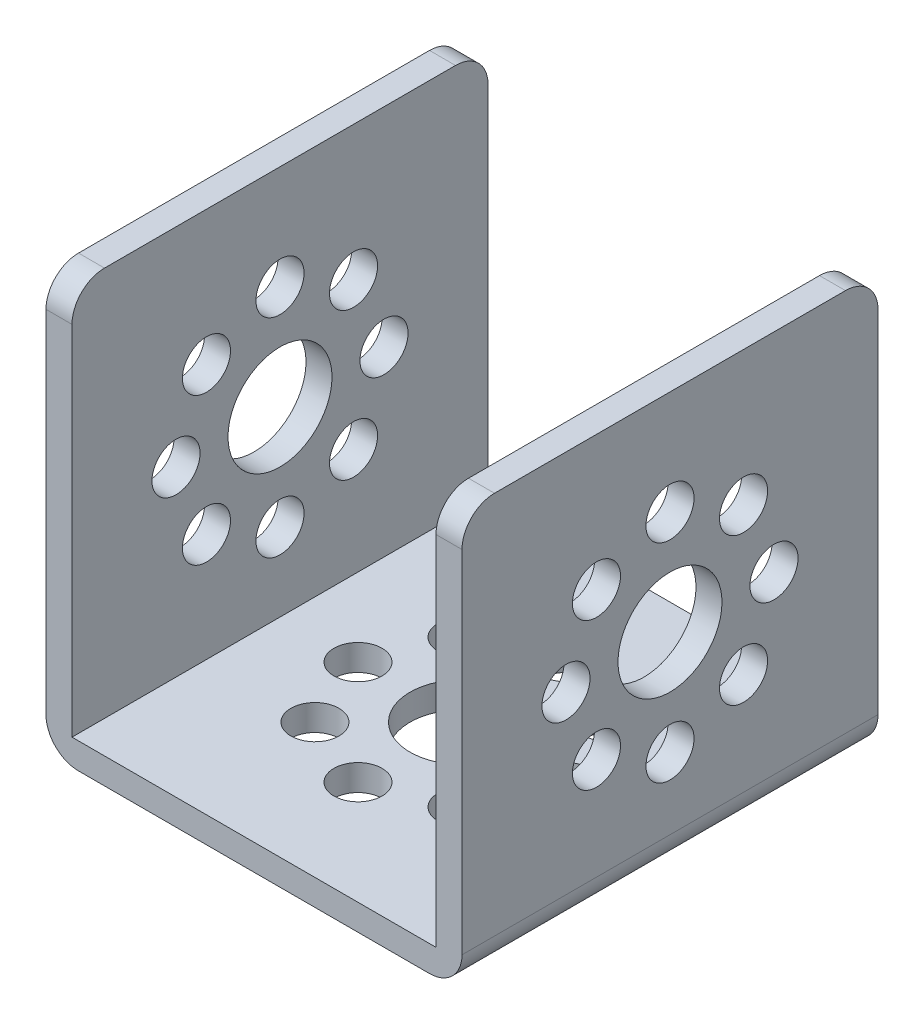
from build123d import *

# Parameters (mm, degrees)
SKETCH1_W                      = 32
SKETCH1_H                      = 32
BOSS_EXTRUDE1_DEPTH            = 32
SKETCH2_W                      = 28
SKETCH2_H                      = 30
CUT_EXTRUDE1_DEPTH             = 33
F_8_0_8_DIAMETER_HOLE1_D       = 8
F_8_0_8_DIAMETER_HOLE1_DEPTH   = 2
F_3_7_3_7_DIAMETER_HOLE1_D     = 3.7
F_3_7_3_7_DIAMETER_HOLE1_DEPTH = 2
F_3_7_3_7_DIAMETER_HOLE2_D     = 3.7
F_3_7_3_7_DIAMETER_HOLE2_DEPTH = 2
F_8_0_8_DIAMETER_HOLE2_D       = 8
F_8_0_8_DIAMETER_HOLE2_DEPTH   = 32
F_8_0_8_DIAMETER_HOLE3_D       = 8
F_8_0_8_DIAMETER_HOLE3_DEPTH   = 32
F_3_7_3_7_DIAMETER_HOLE3_D     = 3.7
F_3_7_3_7_DIAMETER_HOLE3_DEPTH = 32
FILLET1_R                      = 2.5


with BuildPart() as part:
    # Sketch1 → Boss-Extrude1 (new body)
    with BuildSketch(Plane(origin=(16, 0, 0), x_dir=(0, 0, -1), z_dir=(1, 0, 0))):
        with Locations((0, 16)):
            Rectangle(SKETCH1_W, SKETCH1_H)
    extrude(amount=-BOSS_EXTRUDE1_DEPTH)

    # Sketch2 → Cut-Extrude1 (cut, through all)
    with BuildSketch(Plane(origin=(0, 0, -16), x_dir=(-1, 0, 0), z_dir=(0, 0, -1))):
        with Locations((0, 17)):
            Rectangle(SKETCH2_W, SKETCH2_H)
    extrude(amount=-CUT_EXTRUDE1_DEPTH, mode=Mode.SUBTRACT)

    # Ø8.0 (8) Diameter Hole1
    with Locations(Plane.ZY.offset(16)):
        with Locations((0, 16)):
            Hole(F_8_0_8_DIAMETER_HOLE1_D / 2, depth=F_8_0_8_DIAMETER_HOLE1_DEPTH)

    # Ø3.7 (3.7) Diameter Hole1
    with Locations(Plane.ZY.offset(16)):
        with Locations((-8, 16), (0, 24), (8, 16), (0, 8), (-5.656854249, 21.656854249), (5.656854249, 21.656854249), (5.656854249, 10.343145751), (-5.656854249, 10.343145751)):
            Hole(F_3_7_3_7_DIAMETER_HOLE1_D / 2, depth=F_3_7_3_7_DIAMETER_HOLE1_DEPTH)

    # Ø3.7 (3.7) Diameter Hole2
    with Locations(Plane(origin=(0, 2, 0), x_dir=(1, 0, 0), z_dir=(0, 1, 0))):
        with Locations((8, 0), (0, 8), (-8, 0), (0, -8), (5.656854249, 5.656854249), (-5.656854249, 5.656854249), (-5.656854249, -5.656854249), (5.656854249, -5.656854249)):
            Hole(F_3_7_3_7_DIAMETER_HOLE2_D / 2, depth=F_3_7_3_7_DIAMETER_HOLE2_DEPTH)

    # Ø8.0 (8) Diameter Hole2
    with Locations(Plane(origin=(0, 0, 0), x_dir=(-1, 0, 0), z_dir=(0, -1, 0))):
        with Locations((0, 0)):
            Hole(F_8_0_8_DIAMETER_HOLE2_D / 2, depth=F_8_0_8_DIAMETER_HOLE2_DEPTH)

    # Ø8.0 (8) Diameter Hole3
    with Locations(Plane(origin=(16, 0, 0), x_dir=(0, 0, -1), z_dir=(1, 0, 0))):
        with Locations((0, 16)):
            Hole(F_8_0_8_DIAMETER_HOLE3_D / 2, depth=F_8_0_8_DIAMETER_HOLE3_DEPTH)

    # Ø3.7 (3.7) Diameter Hole3
    with Locations(Plane(origin=(16, 0, 0), x_dir=(0, 0, -1), z_dir=(1, 0, 0))):
        with Locations((8, 16), (0, 24), (-8, 16), (0, 8), (5.656854249, 21.656854249), (-5.656854249, 21.656854249), (-5.656854249, 10.343145751), (5.656854249, 10.343145751)):
            Hole(F_3_7_3_7_DIAMETER_HOLE3_D / 2, depth=F_3_7_3_7_DIAMETER_HOLE3_DEPTH)

    # Fillet1
    fillet1_edges = [part.edges().sort_by_distance(p)[0] for p in [
        (-16, 0, 0),
        (15, 32, 16),
        (15, 32, -16),
        (16, 0, 0),
        (-15, 32, -16),
        (-15, 32, 16),
    ]]
    fillet(fillet1_edges, radius=FILLET1_R)


solid = part.part
